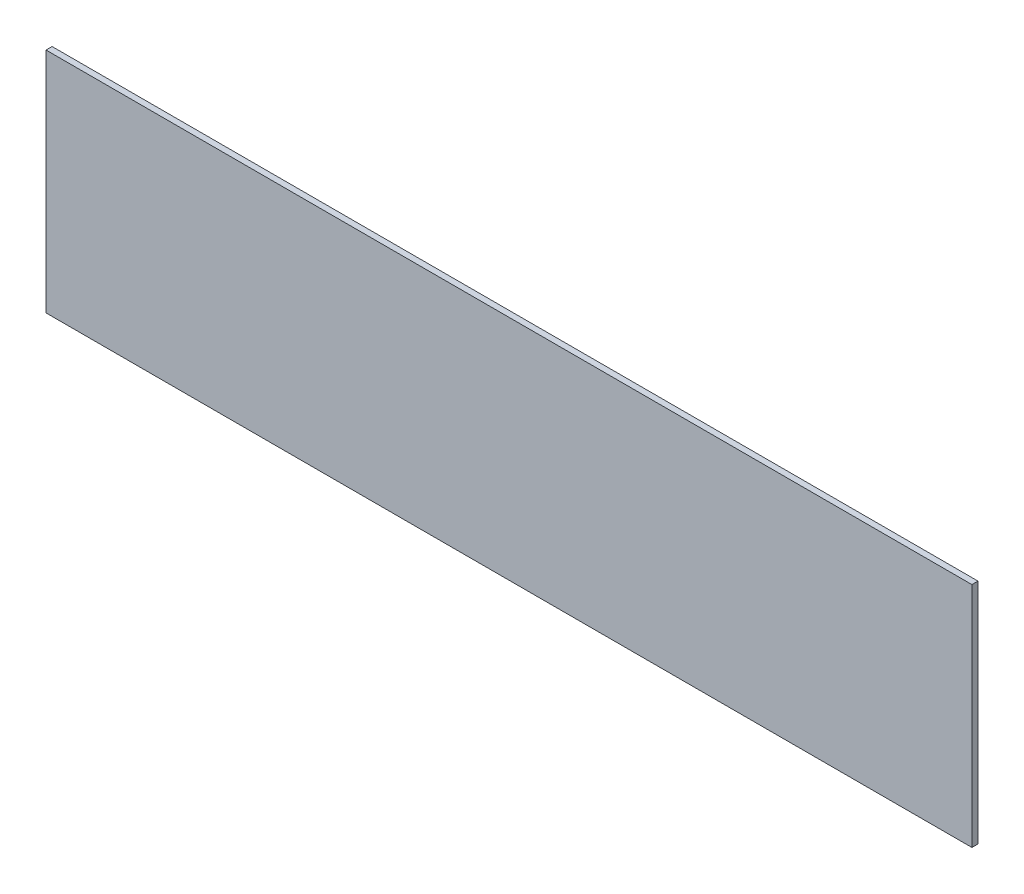
from build123d import *

# Parameters (mm, degrees)
ESBO_O1_W                = 610
ESBO_O1_H                = 150
RESSALTO_EXTRUS_O1_DEPTH = 4


with BuildPart() as part:
    # Esboço1 → Ressalto-extrusão1 (new body)
    with BuildSketch(Plane.XY):
        Rectangle(ESBO_O1_W, ESBO_O1_H)
    extrude(amount=RESSALTO_EXTRUS_O1_DEPTH)


solid = part.part
